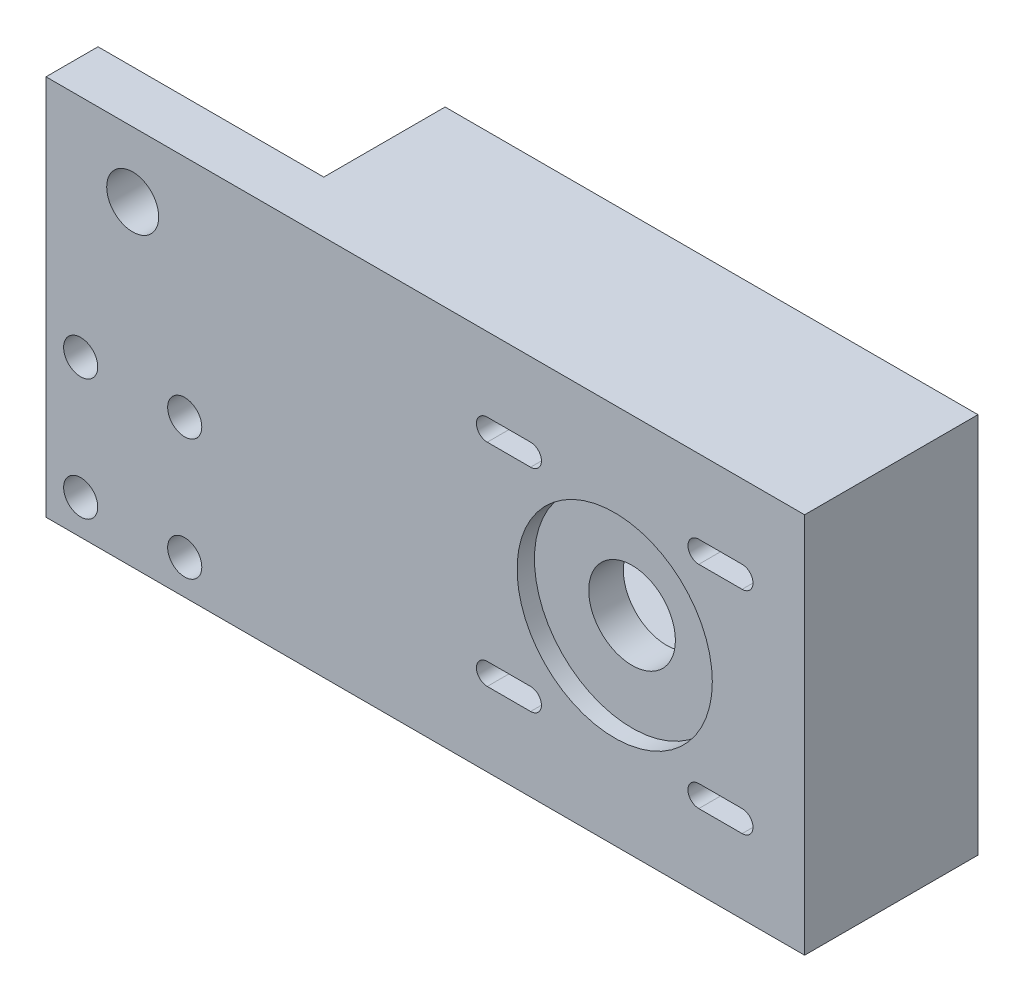
from build123d import *

# Parameters (mm, degrees)
SKETCH2_W           = 111.125
SKETCH2_H           = 55.88
SKETCH2_R           = 3.81
BOSS_EXTRUDE1_DEPTH = 25.4
SKETCH4_R           = 15.24
CUT_EXTRUDE2_DEPTH  = 17.78
CUT_EXTRUDE3_DEPTH  = 17.78
SKETCH6_R           = 6.35
CUT_EXTRUDE4_DEPTH  = 20.32
SKETCH7_R           = 14.3002
CUT_EXTRUDE5_DEPTH  = 2.54
SKETCH8_R           = 6.35
CUT_EXTRUDE6_DEPTH  = 23.86
SKETCH9_R           = 11.43
SKETCH9_R_2         = 6.35
CUT_EXTRUDE7_DEPTH  = 17.78
SKETCH10_R          = 2.5
CUT_EXTRUDE8_DEPTH  = 26.4


with BuildPart() as part:
    # Sketch2 → Boss-Extrude1 (new body)
    with BuildSketch(Plane.XY):
        with Locations((55.5625, 27.94)):
            Rectangle(SKETCH2_W, SKETCH2_H)
        with Locations((12.7, 46.355)):
            Circle(SKETCH2_R, mode=Mode.SUBTRACT)
        with BuildLine():
            Line((70.988225187, 41.8465), (64.638225187, 41.8465))
            ThreePointArc((64.638225187, 41.8465), (63.050725187, 43.434), (64.638225187, 45.0215))
            Line((64.638225187, 45.0215), (70.988225187, 45.0215))
            ThreePointArc((70.988225187, 45.0215), (72.575725187, 43.434), (70.988225187, 41.8465))
        make_face(mode=Mode.SUBTRACT)
        with BuildLine():
            Line((101.976225187, 41.8465), (95.626225187, 41.8465))
            ThreePointArc((95.626225187, 41.8465), (94.038725187, 43.434), (95.626225187, 45.0215))
            Line((95.626225187, 45.0215), (101.976225187, 45.0215))
            ThreePointArc((101.976225187, 45.0215), (103.563725187, 43.434), (101.976225187, 41.8465))
        make_face(mode=Mode.SUBTRACT)
        with BuildLine():
            Line((101.976225187, 10.8585), (95.626225187, 10.8585))
            ThreePointArc((95.626225187, 10.8585), (94.038725187, 12.446), (95.626225187, 14.0335))
            Line((95.626225187, 14.0335), (101.976225187, 14.0335))
            ThreePointArc((101.976225187, 14.0335), (103.563725187, 12.446), (101.976225187, 10.8585))
        make_face(mode=Mode.SUBTRACT)
        with BuildLine():
            Line((70.988225187, 10.8585), (64.638225187, 10.8585))
            ThreePointArc((64.638225187, 10.8585), (63.050725187, 12.446), (64.638225187, 14.0335))
            Line((64.638225187, 14.0335), (70.988225187, 14.0335))
            ThreePointArc((70.988225187, 14.0335), (72.575725187, 12.446), (70.988225187, 10.8585))
        make_face(mode=Mode.SUBTRACT)
    extrude(amount=BOSS_EXTRUDE1_DEPTH)

    # Sketch4 → Cut-Extrude2 (cut)
    with BuildSketch(Plane(origin=(0, 0, 0), x_dir=(-1, 0, 0), z_dir=(0, 0, -1))):
        with Locations((-12.7, 46.355)):
            Circle(SKETCH4_R)
    extrude(amount=-CUT_EXTRUDE2_DEPTH, mode=Mode.SUBTRACT)

    # Sketch5 → Cut-Extrude3 (cut)
    with BuildSketch(Plane(origin=(0, 0, 0), x_dir=(-1, 0, 0), z_dir=(0, 0, -1))):
        with BuildLine():
            Line((0, 54.779226968), (0, 55.88))
            Line((0, 55.88), (-0.803278813, 55.88))
            ThreePointArc((-0.803278813, 55.88), (-0.389329888, 55.33859624), (0, 54.779226968))
        make_face()
    extrude(amount=-CUT_EXTRUDE3_DEPTH, mode=Mode.SUBTRACT)

    # Sketch6 → Cut-Extrude4 (cut)
    with BuildSketch(Plane(origin=(0, 0, 0), x_dir=(-1, 0, 0), z_dir=(0, 0, -1))):
        with Locations((-98.801225187, 43.434)):
            Circle(SKETCH6_R)
        with Locations((-98.801225187, 12.446)):
            Circle(SKETCH6_R)
        with Locations((-67.813225187, 43.434)):
            Circle(SKETCH6_R)
        with Locations((-67.813225187, 12.446)):
            Circle(SKETCH6_R)
    extrude(amount=-CUT_EXTRUDE4_DEPTH, mode=Mode.SUBTRACT)

    # Sketch7 → Cut-Extrude5 (cut)
    with BuildSketch(Plane.XY.offset(25.4)):
        with Locations((83.307225187, 27.94)):
            Circle(SKETCH7_R)
    extrude(amount=-CUT_EXTRUDE5_DEPTH, mode=Mode.SUBTRACT)

    # Sketch8 → Cut-Extrude6 (cut, through all)
    with BuildSketch(Plane.XY.offset(22.86)):
        with Locations((83.307225187, 27.94)):
            Circle(SKETCH8_R)
    extrude(amount=-CUT_EXTRUDE6_DEPTH, mode=Mode.SUBTRACT)

    # Sketch9 → Cut-Extrude7 (cut)
    with BuildSketch(Plane(origin=(0, 0, 0), x_dir=(-1, 0, 0), z_dir=(0, 0, -1))):
        with Locations((-83.307225187, 27.94)):
            Circle(SKETCH9_R)
        with Locations((-83.307225187, 27.94)):
            Circle(SKETCH9_R_2, mode=Mode.SUBTRACT)
        with BuildLine():
            Line((-74.135687658, 42.843264609), (-86.765332472, 38.834328525))
            ThreePointArc((-86.765332472, 38.834328525), (-76.557457275, 37.164181976), (-71.877225187, 27.94))
            ThreePointArc((-71.877225187, 27.94), (-74.448057171, 20.717809053), (-81.004091691, 16.744443913))
            Line((-81.004091691, 16.744443913), (-9.629155339, 31.427591884))
            ThreePointArc((-9.629155339, 31.427591884), (-25.698234103, 38.398649693), (-24.596721187, 55.88))
            Line((-24.596721187, 55.88), (-33.065105822, 55.88))
            Line((-33.065105822, 55.88), (-62.307510769, 46.597796572))
            ThreePointArc((-62.307510769, 46.597796572), (-61.677926231, 45.071255852), (-61.463225187, 43.434))
            ThreePointArc((-61.463225187, 43.434), (-67.517536745, 37.090888118), (-74.135687658, 42.843264609))
        make_face()
    extrude(amount=-CUT_EXTRUDE7_DEPTH, mode=Mode.SUBTRACT)

    # Sketch10 → Cut-Extrude8 (cut, through all)
    with BuildSketch(Plane.XY.offset(25.4)):
        with Locations((5.08, 5.08)):
            Circle(SKETCH10_R)
        with Locations((20.32, 5.08)):
            Circle(SKETCH10_R)
        with Locations((20.32, 22.86)):
            Circle(SKETCH10_R)
        with Locations((5.08, 22.86)):
            Circle(SKETCH10_R)
    extrude(amount=-CUT_EXTRUDE8_DEPTH, mode=Mode.SUBTRACT)


solid = part.part
